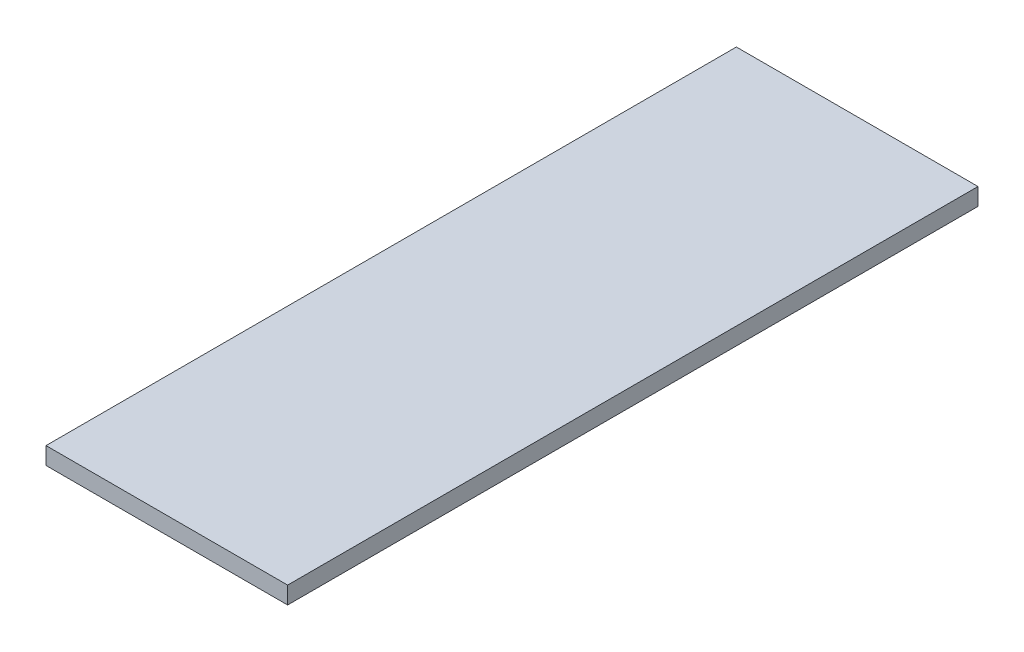
from build123d import *

# Parameters (mm, degrees)
SKETCH1_W           = 70
SKETCH1_H           = 200
BOSS_EXTRUDE1_DEPTH = 5


with BuildPart() as part:
    # Sketch1 → Boss-Extrude1 (new body)
    with BuildSketch(Plane(origin=(0, 0, 0), x_dir=(1, 0, 0), z_dir=(0, 1, 0))):
        with Locations((51.23853211, 0.458715596)):
            Rectangle(SKETCH1_W, SKETCH1_H)
    extrude(amount=BOSS_EXTRUDE1_DEPTH)


solid = part.part
